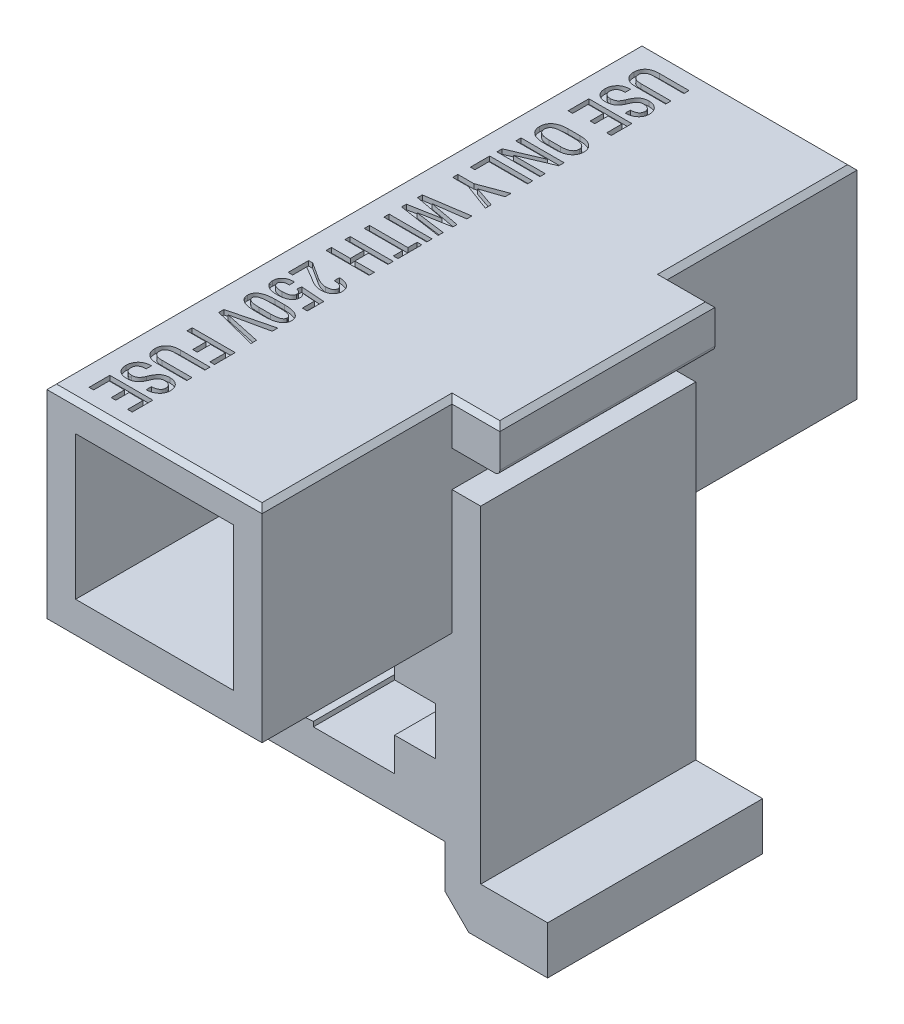
from build123d import *

# Parameters (mm, degrees)
SKETCH_1_W          = 6.6
SKETCH_1_H          = 6
EXTRUDE_910_DEPTH   = 4.5
SKETCH_2_W          = 9
SKETCH_2_H          = 8.5
SKETCH_2_W_2        = 6.6
SKETCH_2_H_2        = 6
EXTRUDE_1336_DEPTH  = 12.45
EXTRUDE_1612_DEPTH  = 2.5
FILLET_1_R          = 0.2
SKETCH_5_W          = 1.8
SKETCH_5_H          = 0.220879121
CUT_EXTRUDE_2_DEPTH = 0.2
CHAMFER_1_SIZE      = 0.2


with BuildPart() as part:
    # Эскиз1 → Extrude 910 (new, symmetric)
    with BuildSketch(Plane.XY):
        Polygon((0, -10), (3.2, -10.2), (3.2, -10), (6.6, -10), (6.6, -11.4), (8.3, -11.4), (8.3, -13.4), (6.6, -13.4), (6.6, -14.8), (3.2, -14.8), (3.2, -14.6), (0, -14.8), (0, -16.2), (8.7, -16.2), (8.7, -18), (9.7, -19), (13, -19), (13, -17), (10.2, -17), (10.2, -3.3), (9, -3.3), (9, -1.8), (11, -1.8), (11, 0), (0, 0), align=None)
        with Locations((4.5, -4.2)):
            Rectangle(SKETCH_1_W, SKETCH_1_H, mode=Mode.SUBTRACT)
    extrude(amount=EXTRUDE_910_DEPTH, both=True)

    # Эскиз2 → Extrude 1336 (add, symmetric)
    with BuildSketch(Plane.XY):
        with Locations((4.5, -4.25)):
            Rectangle(SKETCH_2_W, SKETCH_2_H)
        with Locations((4.5, -4.2)):
            Rectangle(SKETCH_2_W_2, SKETCH_2_H_2, mode=Mode.SUBTRACT)
    extrude(amount=EXTRUDE_1336_DEPTH, both=True)

    # Эскиз3 → Extrude 1612 (add, symmetric)
    with BuildSketch(Plane.XY):
        with BuildLine():
            Line((2.5, -1.2), (2.5, -2.234463617))
            ThreePointArc((2.5, -2.234463617), (2.654992936, -2.497090636), (2.959819676, -2.48834877))
            add(Edge.make_bspline(
                [(6.040180324, -2.48834877), (4.5, -1.518811493), (2.959819676, -2.48834877)],
                knots=[0.437087375, 0.437087375, 0.437087375, 2.704505279, 2.704505279, 2.704505279], degree=2, weights=[1, 0.423302459, 1]))
            ThreePointArc((6.040180324, -2.48834877), (6.345007064, -2.497090636), (6.5, -2.234463617))
            Line((6.5, -2.234463617), (6.5, -1.2))
            Line((6.5, -1.2), (2.5, -1.2))
        make_face()
    extrude(amount=EXTRUDE_1612_DEPTH, both=True)

    # Скругление1
    fillet_1_edges = [part.edges().sort_by_distance(p)[0] for p in [
        (11, -1.8, 0),
    ]]
    fillet(fillet_1_edges, radius=FILLET_1_R)

    # Эскиз5 → Вырез-Вытянуть2 (cut)
    # profile 1 of 19: a face of its own
    with BuildSketch(Plane(origin=(0, 0, 0), x_dir=(1, 0, 0), z_dir=(0, 1, 0))):
        with BuildLine():
            Line((2.8, 10.643956044), (1.552747253, 10.643956044))
            add(Edge.make_bspline(
                [(1.552747253, 10.643956044), (1.529653086, 10.644368303), (1.484842464, 10.645168227), (1.419756028, 10.651613462), (1.358826488, 10.661298779), (1.302526713, 10.676786872), (1.250213908, 10.694960296), (1.20262485, 10.71844193), (1.158965451, 10.745405837), (1.120209836, 10.777175483), (1.085568874, 10.811940625), (1.055747754, 10.850032833), (1.030210482, 10.890822826), (1.00981077, 10.934725437), (0.993486787, 10.981055202), (0.982277417, 11.030339595), (0.975090921, 11.082326443), (0.974363611, 11.118046199), (0.973992674, 11.136263736)],
                knots=[0, 0, 0, 0, 1.285713227, 2.494725674, 3.639351386, 4.716346927, 5.742228908, 6.718347468, 7.665379, 8.59347588, 9.502167367, 10.39310791, 11.281762387, 12.175991834, 13.08343601, 14.011981089, 14.986084709, 16, 16, 16, 16], degree=3))
            add(Edge.make_bspline(
                [(0.973992674, 11.136263736), (0.974353355, 11.154238887), (0.975057974, 11.189354729), (0.982362134, 11.240591464), (0.993435044, 11.289172484), (1.009727494, 11.334807518), (1.030325585, 11.377764389), (1.055748018, 11.41775907), (1.085598491, 11.455103261), (1.120221879, 11.489160116), (1.159098741, 11.520142984), (1.202627081, 11.546783975), (1.250240581, 11.569860769), (1.302535915, 11.58771112), (1.358886389, 11.602673739), (1.419725805, 11.612640189), (1.4848683, 11.618426816), (1.529658019, 11.619319855), (1.552747253, 11.61978022)],
                knots=[0, 0, 0, 0, 1.008087759, 1.969377174, 2.898453435, 3.80001039, 4.682620536, 5.566559556, 6.453679748, 7.359730165, 8.286453594, 9.237208886, 10.217911946, 11.249456112, 12.333052902, 13.486557869, 14.704313053, 16, 16, 16, 16], degree=3))
            Line((1.552747253, 11.61978022), (2.8, 11.61978022))
            Line((2.8, 11.61978022), (2.8, 11.402197802))
            Line((2.8, 11.402197802), (1.552747253, 11.402197802))
            add(Edge.make_bspline(
                [(1.552747253, 11.402197802), (1.536868265, 11.402002615), (1.506172722, 11.401625301), (1.461654611, 11.398288706), (1.420303904, 11.39288154), (1.381894105, 11.385378703), (1.346854182, 11.374969089), (1.314591619, 11.363205809), (1.285985388, 11.348240996), (1.26001764, 11.3319831), (1.237691352, 11.313047156), (1.218078412, 11.292867415), (1.201388576, 11.271041017), (1.187616808, 11.247495737), (1.177520182, 11.221827321), (1.169662611, 11.194777568), (1.1652982, 11.165952959), (1.164748925, 11.146289585), (1.164468864, 11.136263736)],
                knots=[0, 0, 0, 0, 1.433081564, 2.77027844, 4.026549566, 5.195842378, 6.297919398, 7.323384151, 8.289447543, 9.206558402, 10.082830922, 10.924604247, 11.742372131, 12.557089603, 13.377748575, 14.225488684, 15.095222285, 16, 16, 16, 16], degree=3))
            add(Edge.make_bspline(
                [(1.164468864, 11.136263736), (1.164722226, 11.125743617), (1.165216564, 11.105217686), (1.169877557, 11.075445834), (1.176530033, 11.04727459), (1.187041973, 11.021220687), (1.199945241, 10.996717583), (1.215632984, 10.973926129), (1.234618931, 10.953259504), (1.256465223, 10.934421987), (1.281403684, 10.917428493), (1.310138258, 10.903268986), (1.341914003, 10.890695254), (1.377494342, 10.881107633), (1.416331119, 10.87284917), (1.458861358, 10.867685107), (1.504706016, 10.864298292), (1.536378949, 10.863927754), (1.552747253, 10.863736264)],
                knots=[0, 0, 0, 0, 0.935379452, 1.825030123, 2.676164598, 3.505381383, 4.317045097, 5.136812626, 5.959741963, 6.807053905, 7.699023536, 8.636797684, 9.651649978, 10.735134006, 11.911341456, 13.182146826, 14.543757403, 16, 16, 16, 16], degree=3))
            Line((1.552747253, 10.863736264), (2.8, 10.863736264))
            Line((2.8, 10.863736264), (2.8, 10.643956044))
        make_face()
    # profile 2 of 19: a face of its own
    with BuildSketch(Plane(origin=(0, 0, 0), x_dir=(1, 0, 0), z_dir=(0, 1, 0))):
        with BuildLine():
            add(Edge.make_bspline(
                [(1.452380952, 9.684249084), (1.473064094, 9.684920037), (1.512652304, 9.686204263), (1.5689084, 9.696761137), (1.618982792, 9.714637352), (1.655696041, 9.736411729), (1.682483941, 9.757443717), (1.7012975, 9.776786103), (1.720132094, 9.798465473), (1.738420569, 9.823043239), (1.755997544, 9.850609418), (1.772752697, 9.881190398), (1.789292628, 9.914538021), (1.799494976, 9.938046812), (1.804761905, 9.95018315)],
                knots=[0, 0, 0, 0, 1.562131304, 2.989970457, 4.306494377, 5.559837698, 6.19678473, 6.875347781, 7.594954274, 8.366353833, 9.187992889, 10.063608961, 11.000344366, 12, 12, 12, 12], degree=3))
            add(Edge.make_bspline(
                [(1.804761905, 9.95018315), (1.811423262, 9.96820156), (1.824456909, 10.003456479), (1.84649437, 10.0538813), (1.869655852, 10.101093052), (1.893986576, 10.145023966), (1.920117106, 10.185478734), (1.947464614, 10.22249229), (1.976337108, 10.256045613), (2.006217713, 10.286826807), (2.038830116, 10.313711953), (2.073590052, 10.337399691), (2.111566376, 10.356908175), (2.152066476, 10.372938377), (2.19539677, 10.385367722), (2.241175293, 10.394638248), (2.289876937, 10.399623405), (2.32318858, 10.400356288), (2.34029304, 10.400732601)],
                knots=[0, 0, 0, 0, 1.217935212, 2.383018656, 3.487592294, 4.551698414, 5.565372946, 6.539388828, 7.467357411, 8.370710179, 9.255964568, 10.142842657, 11.032824559, 11.957298199, 12.900643214, 13.88762046, 14.915360815, 16, 16, 16, 16], degree=3))
            add(Edge.make_bspline(
                [(2.34029304, 10.400732601), (2.358018992, 10.400464833), (2.392732587, 10.399940451), (2.443306075, 10.393385043), (2.491388362, 10.383614181), (2.536844995, 10.369795114), (2.579750453, 10.35163059), (2.620000035, 10.329682151), (2.657883796, 10.30389011), (2.692275502, 10.273795119), (2.724055514, 10.241089744), (2.751054445, 10.204905667), (2.774385047, 10.166579279), (2.793639297, 10.125636752), (2.808194828, 10.081959658), (2.818365075, 10.035786274), (2.824742147, 9.987234865), (2.825579408, 9.953988373), (2.826007326, 9.936996337)],
                knots=[0, 0, 0, 0, 1.124515011, 2.202192552, 3.231281813, 4.236481171, 5.212480952, 6.183637031, 7.142467189, 8.115137586, 9.079963614, 10.031750853, 10.974182522, 11.924232489, 12.89727338, 13.890115663, 14.921653751, 16, 16, 16, 16], degree=3))
            add(Edge.make_bspline(
                [(2.826007326, 9.936996337), (2.825510307, 9.919509296), (2.824536087, 9.885232454), (2.817020719, 9.835146257), (2.805026334, 9.787716924), (2.788192722, 9.74296737), (2.765847014, 9.70112035), (2.738681257, 9.662026205), (2.706977757, 9.625301825), (2.670269685, 9.592261753), (2.630099752, 9.562529919), (2.587598437, 9.535798636), (2.542284105, 9.513904076), (2.4946829, 9.495945187), (2.444780274, 9.481402293), (2.392216702, 9.47194364), (2.337413167, 9.465242011), (2.300021615, 9.464729989), (2.280952381, 9.464468864)],
                knots=[0, 0, 0, 0, 1.036885918, 2.03242926, 2.996767969, 3.934272482, 4.860859703, 5.803052047, 6.752785154, 7.731993726, 8.725638583, 9.714415197, 10.705549545, 11.70493152, 12.729579591, 13.783523999, 14.869624365, 16, 16, 16, 16], degree=3))
            Line((2.280952381, 9.464468864), (2.280952381, 9.685347985))
            add(Edge.make_bspline(
                [(2.280952381, 9.685347985), (2.294021679, 9.685582917), (2.319461193, 9.686040214), (2.356669434, 9.68889894), (2.391758971, 9.694074034), (2.424980137, 9.700927582), (2.456231449, 9.710085794), (2.485489526, 9.721422907), (2.512712372, 9.734616425), (2.537857537, 9.749639378), (2.560514877, 9.76676855), (2.580508516, 9.785795656), (2.597138481, 9.806966606), (2.610826436, 9.829855891), (2.621477893, 9.854622985), (2.629254633, 9.8811633), (2.633623041, 9.909622588), (2.63415786, 9.929167269), (2.634432234, 9.939194139)],
                knots=[0, 0, 0, 0, 1.278996757, 2.48957959, 3.64877324, 4.747844577, 5.806488387, 6.831629009, 7.814900639, 8.76366329, 9.6932724, 10.589014924, 11.456745892, 12.319444101, 13.191769743, 14.087910641, 15.019054267, 16, 16, 16, 16], degree=3))
            add(Edge.make_bspline(
                [(2.634432234, 9.939194139), (2.634304728, 9.948736259), (2.634056632, 9.967302969), (2.629730135, 9.994134199), (2.623612001, 10.019345354), (2.614935783, 10.042804116), (2.603328765, 10.06439319), (2.589274712, 10.084276169), (2.57289242, 10.102733074), (2.5469051, 10.124209563), (2.510167636, 10.14726782), (2.459452978, 10.166170912), (2.403005474, 10.178186859), (2.363191638, 10.179283363), (2.342490842, 10.17985348)],
                knots=[0, 0, 0, 0, 0.802021316, 1.560543999, 2.280728389, 2.983026886, 3.658741603, 4.337184916, 5.028346535, 5.728235768, 7.16805474, 8.654485078, 10.260533812, 12, 12, 12, 12], degree=3))
            add(Edge.make_bspline(
                [(2.342490842, 10.17985348), (2.323731557, 10.179177187), (2.287472252, 10.177869999), (2.235581965, 10.164993619), (2.188581526, 10.144053923), (2.153974617, 10.119024937), (2.128585188, 10.095079173), (2.109948216, 10.074043358), (2.091533299, 10.050289432), (2.074291962, 10.02315157), (2.055902964, 9.9940462), (2.039112162, 9.961330936), (2.022048054, 9.926120575), (2.011609466, 9.90139416), (2.006227106, 9.888644689)],
                knots=[0, 0, 0, 0, 1.411650332, 2.728539836, 4.001213019, 5.267849563, 5.925377249, 6.629249922, 7.383929009, 8.187943363, 9.051283996, 9.977518369, 10.957165011, 12, 12, 12, 12], degree=3))
            add(Edge.make_bspline(
                [(2.006227106, 9.888644689), (1.999710993, 9.871347374), (1.986952192, 9.837478563), (1.964902375, 9.789232487), (1.941428425, 9.744351892), (1.916461442, 9.702685771), (1.889845888, 9.664340109), (1.861682921, 9.629203201), (1.831283842, 9.598112361), (1.799943605, 9.569446231), (1.765721334, 9.54487462), (1.729458781, 9.522865978), (1.689989461, 9.50533636), (1.648323288, 9.489773745), (1.603609841, 9.478974686), (1.556459664, 9.470194188), (1.506557811, 9.465687716), (1.47241248, 9.464881363), (1.454945055, 9.464468864)],
                knots=[0, 0, 0, 0, 1.179928657, 2.310345955, 3.384407641, 4.412585788, 5.409581103, 6.36294743, 7.283720604, 8.183663037, 9.070954501, 9.969443695, 10.886943557, 11.824106363, 12.805463855, 13.819355269, 14.884466877, 16, 16, 16, 16], degree=3))
            add(Edge.make_bspline(
                [(1.454945055, 9.464468864), (1.43660896, 9.464732339), (1.40080045, 9.465246879), (1.348645373, 9.47182358), (1.299598654, 9.481480823), (1.253477848, 9.495035414), (1.210709751, 9.513037066), (1.170729294, 9.534751531), (1.133903974, 9.560456905), (1.100576086, 9.590196954), (1.07086324, 9.623334813), (1.044680384, 9.659152297), (1.023105174, 9.698070113), (1.004923386, 9.739307753), (0.991002836, 9.783541977), (0.981391224, 9.830568051), (0.9747733, 9.880155046), (0.974256611, 9.914140979), (0.973992674, 9.931501832)],
                knots=[0, 0, 0, 0, 1.158591607, 2.262610455, 3.317834137, 4.316776784, 5.295987146, 6.246006859, 7.188311029, 8.128779395, 9.063495607, 9.997701637, 10.927463686, 11.871189725, 12.842885681, 13.852745409, 14.903129434, 16, 16, 16, 16], degree=3))
            add(Edge.make_bspline(
                [(0.973992674, 9.931501832), (0.974398743, 9.948618597), (0.975199481, 9.982371611), (0.982035159, 10.032028041), (0.992840417, 10.079961428), (1.008852862, 10.125837908), (1.028745704, 10.170124098), (1.052797811, 10.212819625), (1.082171182, 10.253021255), (1.114818979, 10.291667646), (1.152197546, 10.326794793), (1.19366701, 10.357864682), (1.239668538, 10.383470715), (1.289330812, 10.404850311), (1.343147118, 10.421316277), (1.400841609, 10.43271621), (1.462428519, 10.440458798), (1.504858601, 10.441074448), (1.526739927, 10.441391941)],
                knots=[0, 0, 0, 0, 0.970082726, 1.912932519, 2.836550248, 3.751671045, 4.662645183, 5.586574191, 6.524122738, 7.481499719, 8.451187138, 9.425927293, 10.411692308, 11.428873971, 12.486524008, 13.595751359, 14.760121493, 16, 16, 16, 16], degree=3))
            Line((1.526739927, 10.441391941), (1.526739927, 10.220512821))
            add(Edge.make_bspline(
                [(1.526739927, 10.220512821), (1.511347738, 10.220347189), (1.481736435, 10.220028549), (1.438895167, 10.216333607), (1.399378274, 10.210124474), (1.362923231, 10.201869514), (1.329725237, 10.190968277), (1.299894316, 10.177219609), (1.27289173, 10.161751281), (1.249578539, 10.143089964), (1.229474195, 10.122422346), (1.211649107, 10.100316644), (1.196601277, 10.07649735), (1.184361105, 10.050789312), (1.174857625, 10.023400689), (1.168357449, 9.994138318), (1.164247906, 9.96336406), (1.163666395, 9.942259911), (1.163369963, 9.931501832)],
                knots=[0, 0, 0, 0, 1.396148919, 2.685894102, 3.896984594, 5.022854719, 6.073749873, 7.060199081, 7.99871115, 8.88966808, 9.759156373, 10.610316575, 11.461620932, 12.308879692, 13.188191438, 14.085734925, 15.024181617, 16, 16, 16, 16], degree=3))
            add(Edge.make_bspline(
                [(1.163369963, 9.931501832), (1.163535983, 9.921842091), (1.163860898, 9.902937216), (1.167705952, 9.875491342), (1.173388679, 9.849647637), (1.181847498, 9.825645556), (1.192911779, 9.803563369), (1.206288813, 9.783247201), (1.221659665, 9.764345745), (1.2459646, 9.741750327), (1.282063896, 9.718083017), (1.332605679, 9.69847982), (1.390139595, 9.686209881), (1.430946368, 9.684924341), (1.452380952, 9.684249084)],
                knots=[0, 0, 0, 0, 0.804902542, 1.575257773, 2.306329089, 3.008322246, 3.691304701, 4.360565555, 5.033225263, 5.71749658, 7.120929047, 8.601284655, 10.21475592, 12, 12, 12, 12], degree=3))
        make_face()
    # profile 3 of 19: a face of its own
    with BuildSketch(Plane(origin=(0, 0, 0), x_dir=(1, 0, 0), z_dir=(0, 1, 0))):
        Polygon((1.835897436, 8.447619048), (1.835897436, 9.005860806), (1.19047619, 9.005860806), (1.19047619, 8.357509158), (1, 8.357509158), (1, 9.226739927), (2.8, 9.226739927), (2.8, 8.363003663), (2.607326007, 8.363003663), (2.607326007, 9.005860806), (2.027472527, 9.005860806), (2.027472527, 8.447619048), align=None)
    # profile 4 of 19: a face of its own
    with BuildSketch(Plane(origin=(0, 0, 0), x_dir=(1, 0, 0), z_dir=(0, 1, 0))):
        with BuildLine():
            add(Edge.make_bspline(
                [(1.651648352, 6.678388278), (1.625258379, 6.678775891), (1.573857356, 6.679530863), (1.499254152, 6.68635002), (1.429131391, 6.696584101), (1.363929375, 6.712129911), (1.303111784, 6.731274199), (1.247200374, 6.755353131), (1.195484167, 6.782869353), (1.149277293, 6.815714614), (1.108213104, 6.852113463), (1.071726449, 6.891305104), (1.041677457, 6.934534161), (1.017055076, 6.98070272), (0.997157971, 7.029815043), (0.984112733, 7.082497994), (0.975141127, 7.138154926), (0.974381489, 7.176396831), (0.973992674, 7.195970696)],
                knots=[0, 0, 0, 0, 1.313978048, 2.559298395, 3.728047241, 4.840168003, 5.894005044, 6.89926583, 7.867941638, 8.805995934, 9.714981633, 10.597297047, 11.466098001, 12.328512588, 13.199120512, 14.097323178, 15.026127528, 16, 16, 16, 16], degree=3))
            add(Edge.make_bspline(
                [(0.973992674, 7.195970696), (0.974377784, 7.215300526), (0.975127602, 7.252936161), (0.984081957, 7.307634626), (0.997318841, 7.359398483), (1.016876419, 7.407797248), (1.041702361, 7.453046982), (1.071872595, 7.495189839), (1.108125439, 7.533611161), (1.149315378, 7.568950267), (1.195731485, 7.600542627), (1.24710029, 7.627936564), (1.303240571, 7.650986523), (1.363870457, 7.670097485), (1.429246346, 7.684462088), (1.499216439, 7.695161707), (1.573883775, 7.701269484), (1.625263801, 7.702124855), (1.651648352, 7.702564103)],
                knots=[0, 0, 0, 0, 0.969502548, 1.887644309, 2.775321219, 3.647280498, 4.500507326, 5.361341538, 6.241792457, 7.146057014, 8.081210543, 9.054812977, 10.063448489, 11.123952136, 12.242317787, 13.4205215, 14.67539222, 16, 16, 16, 16], degree=3))
            Line((1.651648352, 7.702564103), (2.146153846, 7.702564103))
            add(Edge.make_bspline(
                [(2.146153846, 7.702564103), (2.172417039, 7.70212951), (2.223554688, 7.701283306), (2.298088135, 7.69509367), (2.367961887, 7.684552903), (2.433313338, 7.670048901), (2.493915892, 7.65090473), (2.550254804, 7.628036911), (2.601782156, 7.60046061), (2.648466081, 7.568815572), (2.690436102, 7.533900472), (2.726452794, 7.494964794), (2.757713041, 7.453527462), (2.782717504, 7.408319403), (2.802236637, 7.35997241), (2.816172353, 7.308465423), (2.824235414, 7.253733678), (2.825407044, 7.216266058), (2.826007326, 7.197069597)],
                knots=[0, 0, 0, 0, 1.318288415, 2.566868808, 3.75096063, 4.863184467, 5.923533954, 6.937687672, 7.911148577, 8.85123492, 9.764710117, 10.64503305, 11.508030526, 12.364100571, 13.230248278, 14.119381983, 15.036469066, 16, 16, 16, 16], degree=3))
            add(Edge.make_bspline(
                [(2.826007326, 7.197069597), (2.825406364, 7.177507467), (2.824232972, 7.139311939), (2.81617269, 7.083488437), (2.802233482, 7.030894612), (2.782744122, 6.981439034), (2.757623302, 6.935109037), (2.726608934, 6.892270803), (2.690467575, 6.852209739), (2.648501108, 6.816202811), (2.601927306, 6.783382403), (2.550267747, 6.755169105), (2.494026769, 6.7313868), (2.433258559, 6.712170823), (2.368076681, 6.696493054), (2.298050461, 6.686418929), (2.223581115, 6.679517381), (2.172422447, 6.678771347), (2.146153846, 6.678388278)],
                knots=[0, 0, 0, 0, 0.972237541, 1.898317176, 2.796289293, 3.670822251, 4.534420997, 5.408532696, 6.293594378, 7.209918381, 8.151087683, 9.120764728, 10.129627484, 11.181387851, 12.285411261, 13.45785677, 14.694677809, 16, 16, 16, 16], degree=3))
            Line((2.146153846, 6.678388278), (1.651648352, 6.678388278))
        make_face()
        with BuildLine():
            add(Edge.make_bspline(
                [(2.14981685, 6.899267399), (2.169116369, 6.899421641), (2.206410027, 6.899719691), (2.260544587, 6.903609547), (2.310977795, 6.909141213), (2.357687419, 6.91764783), (2.400663722, 6.928185487), (2.440089151, 6.940873414), (2.475847062, 6.956223706), (2.507850719, 6.974224188), (2.536303862, 6.994400895), (2.560950651, 7.016745697), (2.581928583, 7.041267359), (2.598821278, 7.06822487), (2.612099941, 7.09742528), (2.621649406, 7.128681177), (2.627231089, 7.162192982), (2.627873753, 7.185204326), (2.628205128, 7.197069597)],
                knots=[0, 0, 0, 0, 1.458012894, 2.817408669, 4.099162608, 5.289958794, 6.402097135, 7.440779738, 8.416018391, 9.337260085, 10.210300907, 11.046284175, 11.844876056, 12.640959069, 13.441945694, 14.262046119, 15.103863963, 16, 16, 16, 16], degree=3))
            add(Edge.make_bspline(
                [(2.628205128, 7.197069597), (2.627870092, 7.208447515), (2.627217468, 7.230610758), (2.621632906, 7.262903836), (2.612186874, 7.29299956), (2.598696977, 7.320888517), (2.581912567, 7.346689715), (2.560897071, 7.370087846), (2.536250795, 7.391326951), (2.507800946, 7.410410528), (2.475716812, 7.427244864), (2.440002065, 7.441857977), (2.400649741, 7.454208019), (2.357715339, 7.464534055), (2.31089321, 7.471902864), (2.260572399, 7.477903665), (2.206390056, 7.481077263), (2.169112244, 7.481477707), (2.14981685, 7.481684982)],
                knots=[0, 0, 0, 0, 0.871900125, 1.698389418, 2.503717588, 3.282545406, 4.066700235, 4.855813006, 5.685424632, 6.555261681, 7.476573926, 8.458844122, 9.509906415, 10.636160325, 11.841247002, 13.141822852, 14.520576921, 16, 16, 16, 16], degree=3))
            Line((2.14981685, 7.481684982), (1.651648352, 7.481684982))
            add(Edge.make_bspline(
                [(1.651648352, 7.481684982), (1.632108852, 7.481474892), (1.594221354, 7.481067523), (1.539185599, 7.477913066), (1.488125188, 7.471940648), (1.440714265, 7.464474879), (1.397261884, 7.454271308), (1.357449501, 7.441834093), (1.321434552, 7.427337577), (1.28928486, 7.410385615), (1.260851209, 7.391436337), (1.236389949, 7.369958155), (1.215644085, 7.346349014), (1.198606187, 7.320466988), (1.185431459, 7.292436114), (1.175668595, 7.262332714), (1.170245036, 7.22986728), (1.169574783, 7.207467563), (1.169230769, 7.195970696)],
                knots=[0, 0, 0, 0, 1.486209938, 2.881792185, 4.190460938, 5.395112332, 6.530467681, 7.582012683, 8.565050898, 9.479024523, 10.341932972, 11.157937373, 11.947729972, 12.725638694, 13.506645785, 14.296711357, 15.125770979, 16, 16, 16, 16], degree=3))
            add(Edge.make_bspline(
                [(1.169230769, 7.195970696), (1.169562741, 7.184105832), (1.170206562, 7.161095279), (1.175780039, 7.127577869), (1.185359273, 7.096342304), (1.198487512, 7.067162498), (1.215753399, 7.040474411), (1.236208838, 7.015759846), (1.260944483, 6.993610619), (1.2891123, 6.97343105), (1.321422385, 6.955854545), (1.357343023, 6.940490103), (1.397257951, 6.927793476), (1.440699549, 6.917224497), (1.488087401, 6.909242674), (1.539205662, 6.903558505), (1.594203843, 6.899741904), (1.63210552, 6.899428827), (1.651648352, 6.899267399)],
                knots=[0, 0, 0, 0, 0.8911907, 1.728362962, 2.543937654, 3.340504024, 4.124446398, 4.925649522, 5.744057957, 6.612280894, 7.523971076, 8.502254607, 9.543929799, 10.66775118, 11.859417063, 13.152327948, 14.531685729, 16, 16, 16, 16], degree=3))
            Line((1.651648352, 6.899267399), (2.14981685, 6.899267399))
        make_face(mode=Mode.SUBTRACT)
    # profile 5 of 19: a face of its own
    with BuildSketch(Plane(origin=(0, 0, 0), x_dir=(1, 0, 0), z_dir=(0, 1, 0))):
        Polygon((1, 5.38021978), (1, 5.6), (2.327838828, 6.165934066), (2.326373626, 6.169230769), (1, 6.169230769), (1, 6.39010989), (2.8, 6.39010989), (2.8, 6.169230769), (1.474725275, 5.603296703), (1.475824176, 5.6), (2.8, 5.6), (2.8, 5.38021978), align=None)
    # profile 6 of 19: a face of its own
    with BuildSketch(Plane(origin=(0, 0, 0), x_dir=(1, 0, 0), z_dir=(0, 1, 0))):
        Polygon((1.19047619, 4.856410256), (1.19047619, 4.268498168), (1, 4.268498168), (1, 5.077289377), (2.8, 5.077289377), (2.8, 4.856410256), align=None)
    # profile 7 of 19: a face of its own
    with BuildSketch(Plane(origin=(0, 0, 0), x_dir=(1, 0, 0), z_dir=(0, 1, 0))):
        Polygon((1.940659341, 3.632600733), (2.8, 3.34029304), (2.8, 3.096336996), (1.649084249, 3.527106227), (1, 3.527106227), (1, 3.744688645), (1.667765568, 3.744688645), (2.8, 4.168864469), (2.8, 3.924908425), align=None)
    # profile 8 of 19: a face of its own
    with BuildSketch(Plane(origin=(0, 0, 0), x_dir=(1, 0, 0), z_dir=(0, 1, 0))):
        Polygon((1.535164835, 1.503296703), (1.535164835, 1.5), (2.8, 1.32967033), (2.8, 1.116483516), (1, 1.389010989), (1, 1.586813187), (2.262271062, 1.821978022), (2.262271062, 1.825274725), (1, 2.06043956), (1, 2.258241758), (2.8, 2.530769231), (2.8, 2.317582418), (1.531501832, 2.145054945), (1.531501832, 2.141758242), (2.8, 1.908791209), (2.8, 1.738461538), align=None)
    # profile 9 of 19: a face of its own
    with BuildSketch(Plane(origin=(0, 0, 0), x_dir=(1, 0, 0), z_dir=(0, 1, 0))):
        with Locations((1.9, 0.757326008)):
            Rectangle(SKETCH_5_W, SKETCH_5_H)
    # profile 10 of 19: a face of its own
    with BuildSketch(Plane(origin=(0, 0, 0), x_dir=(1, 0, 0), z_dir=(0, 1, 0))):
        Polygon((2.607326007, -0.56043956), (2.607326007, -0.171428571), (1, -0.171428571), (1, 0.047252747), (2.607326007, 0.047252747), (2.607326007, 0.435164835), (2.8, 0.435164835), (2.8, -0.56043956), align=None)
    # profile 11 of 19: a face of its own
    with BuildSketch(Plane(origin=(0, 0, 0), x_dir=(1, 0, 0), z_dir=(0, 1, 0))):
        Polygon((1, -1.76996337), (1, -1.549084249), (1.793772894, -1.549084249), (1.793772894, -0.980952381), (1, -0.980952381), (1, -0.76007326), (2.8, -0.76007326), (2.8, -0.980952381), (1.985347985, -0.980952381), (1.985347985, -1.549084249), (2.8, -1.549084249), (2.8, -1.76996337), align=None)
    # profile 12 of 19: a face of its own
    with BuildSketch(Plane(origin=(0, 0, 0), x_dir=(1, 0, 0), z_dir=(0, 1, 0))):
        with BuildLine():
            Line((1, -3.357142857), (1, -2.5))
            Line((1, -2.5), (1.167032967, -2.5))
            Line((1.167032967, -2.5), (1.817216117, -2.917582418))
            add(Edge.make_bspline(
                [(1.817216117, -2.917582418), (1.831241036, -2.92579213), (1.858480049, -2.941736924), (1.898346221, -2.964436367), (1.936160558, -2.985281715), (1.972436721, -3.003111872), (2.006140003, -3.020467462), (2.038239538, -3.034948888), (2.068343559, -3.047393305), (2.105375344, -3.061711862), (2.150596188, -3.075622031), (2.204555836, -3.087947741), (2.258299595, -3.094996718), (2.293998198, -3.096137118), (2.311721612, -3.096703297)],
                knots=[0, 0, 0, 0, 1.098193461, 2.132896823, 3.10026747, 4.015414222, 4.864132133, 5.661735444, 6.394194987, 7.065393678, 8.344206655, 9.587330306, 10.802173213, 12, 12, 12, 12], degree=3))
            add(Edge.make_bspline(
                [(2.311721612, -3.096703297), (2.334711039, -3.096234542), (2.378572499, -3.095340207), (2.440773879, -3.086124757), (2.496083275, -3.071386308), (2.536948219, -3.053610141), (2.565024309, -3.036137626), (2.583091144, -3.022173259), (2.598771285, -3.007185415), (2.61130268, -2.990569758), (2.620991122, -2.972640436), (2.628007031, -2.953542144), (2.632066109, -2.933136078), (2.632663156, -2.919187353), (2.632967033, -2.912087912)],
                knots=[0, 0, 0, 0, 2.010332215, 3.835506842, 5.4865274, 7.007354078, 7.712875454, 8.375344066, 9.002407891, 9.604966045, 10.188176453, 10.779645979, 11.378880043, 12, 12, 12, 12], degree=3))
            add(Edge.make_bspline(
                [(2.632967033, -2.912087912), (2.632737163, -2.903149344), (2.632286527, -2.885626226), (2.627272698, -2.860447263), (2.620009285, -2.836829056), (2.609461492, -2.815037685), (2.595048604, -2.795623409), (2.578700171, -2.777242987), (2.558400931, -2.761644943), (2.535763576, -2.74730648), (2.510221872, -2.734984148), (2.482369958, -2.723872799), (2.45187902, -2.715013033), (2.419203971, -2.7069918), (2.383952185, -2.70201134), (2.34650274, -2.697327397), (2.306505048, -2.69483511), (2.279001603, -2.694617553), (2.264835165, -2.694505495)],
                knots=[0, 0, 0, 0, 0.892226533, 1.749115872, 2.555779177, 3.358091866, 4.153974395, 4.965882701, 5.808310582, 6.70220483, 7.6409594, 8.638106989, 9.69598813, 10.811968, 11.997764812, 13.251155143, 14.584128599, 16, 16, 16, 16], degree=3))
            Line((2.264835165, -2.694505495), (2.264835165, -2.474725275))
            add(Edge.make_bspline(
                [(2.264835165, -2.474725275), (2.284753162, -2.475045546), (2.323691123, -2.475671649), (2.380677499, -2.481484641), (2.435142992, -2.489889411), (2.486837852, -2.502983641), (2.536086487, -2.518863295), (2.582519362, -2.53880263), (2.626288748, -2.562316969), (2.667232362, -2.589268567), (2.704466376, -2.619395055), (2.73718369, -2.652515635), (2.764382603, -2.688939285), (2.787510373, -2.727743142), (2.804603396, -2.770087304), (2.817127302, -2.814909214), (2.824530587, -2.862637757), (2.82550701, -2.895334314), (2.826007326, -2.912087912)],
                knots=[0, 0, 0, 0, 1.195714929, 2.337519273, 3.43686419, 4.502082901, 5.536212681, 6.541342879, 7.53206196, 8.516329613, 9.480538189, 10.40346707, 11.303869151, 12.204271232, 13.108397385, 14.037017317, 14.994174709, 16, 16, 16, 16], degree=3))
            add(Edge.make_bspline(
                [(2.826007326, -2.912087912), (2.825569026, -2.927613959), (2.824712914, -2.957940261), (2.818520276, -3.002070269), (2.807784489, -3.043584461), (2.792897532, -3.082559728), (2.773174894, -3.118693072), (2.749629867, -3.152403273), (2.721500516, -3.18318264), (2.68969808, -3.211484791), (2.653837335, -3.236287993), (2.615096596, -3.258394697), (2.573008659, -3.276620806), (2.528045692, -3.291731465), (2.479981538, -3.303300794), (2.428949477, -3.31178989), (2.37493161, -3.316386388), (2.337981118, -3.317177203), (2.319047619, -3.317582418)],
                knots=[0, 0, 0, 0, 1.016289941, 1.985071554, 2.909852686, 3.81832271, 4.708892892, 5.598170728, 6.503646736, 7.432323297, 8.3792253, 9.352842381, 10.347880174, 11.376667233, 12.454586972, 13.580772723, 14.760383602, 16, 16, 16, 16], degree=3))
            add(Edge.make_bspline(
                [(2.319047619, -3.317582418), (2.292874365, -3.316801293), (2.240615501, -3.31524166), (2.162950903, -3.302810455), (2.086839617, -3.282077885), (2.011126273, -3.253262035), (1.934334054, -3.215386317), (1.852830729, -3.171173477), (1.766813573, -3.118203129), (1.70887529, -3.078751635), (1.678754579, -3.058241758)],
                knots=[0, 0, 0, 0, 0.894210851, 1.785427353, 2.680300092, 3.586322125, 4.549419217, 5.604506896, 6.754641101, 8, 8, 8, 8], degree=3))
            Line((1.678754579, -3.058241758), (1.19047619, -2.775824176))
            Line((1.19047619, -2.775824176), (1.19047619, -3.357142857))
            Line((1.19047619, -3.357142857), (1, -3.357142857))
        make_face()
    # profile 13 of 19: a face of its own
    with BuildSketch(Plane(origin=(0, 0, 0), x_dir=(1, 0, 0), z_dir=(0, 1, 0))):
        with BuildLine():
            Line((1.808424908, -3.595604396), (2.8, -3.669230769))
            Line((2.8, -3.669230769), (2.8, -4.353846154))
            Line((2.8, -4.353846154), (2.593406593, -4.353846154))
            Line((2.593406593, -4.353846154), (2.593406593, -3.851648352))
            Line((2.593406593, -3.851648352), (2.065567766, -3.813186813))
            Line((2.065567766, -3.813186813), (2.064468864, -3.816483516))
            add(Edge.make_bspline(
                [(2.064468864, -3.816483516), (2.078559206, -3.82891413), (2.1067366, -3.853772456), (2.134010123, -3.892678077), (2.15114273, -3.926666848), (2.161116539, -3.954152205), (2.16746654, -3.98361461), (2.168873999, -4.003876395), (2.16959707, -4.014285714)],
                knots=[0, 0, 0, 0, 1.459220969, 2.918101204, 3.662171757, 4.420024236, 5.188300935, 6, 6, 6, 6], degree=3))
            add(Edge.make_bspline(
                [(2.16959707, -4.014285714), (2.16952533, -4.029211494), (2.169384508, -4.058510385), (2.162096736, -4.101080227), (2.150374093, -4.141081529), (2.133839696, -4.178615225), (2.111661338, -4.213270476), (2.084010393, -4.244887939), (2.05209137, -4.274486817), (2.014819835, -4.300674932), (1.973278205, -4.324059893), (1.92771304, -4.344636172), (1.878245798, -4.361658631), (1.824966735, -4.37562965), (1.76791373, -4.386425606), (1.706906822, -4.394508038), (1.642079579, -4.399284428), (1.597566096, -4.399757339), (1.574725275, -4.4)],
                knots=[0, 0, 0, 0, 0.89644804, 1.759702572, 2.586936947, 3.398970892, 4.217949097, 5.051160114, 5.919149964, 6.830071015, 7.783800393, 8.783014735, 9.832819845, 10.92655648, 12.093210945, 13.322972728, 14.626360005, 16, 16, 16, 16], degree=3))
            add(Edge.make_bspline(
                [(1.574725275, -4.4), (1.55249682, -4.399593432), (1.509209282, -4.398801683), (1.44592805, -4.394245007), (1.386177952, -4.385600104), (1.329627731, -4.374629128), (1.276639962, -4.359479557), (1.227102944, -4.341107722), (1.180577054, -4.319975614), (1.137801978, -4.295180522), (1.099109954, -4.267092322), (1.065547499, -4.23551384), (1.037212299, -4.200511741), (1.014116074, -4.162282968), (0.995947514, -4.120795551), (0.983212598, -4.076076776), (0.97535265, -4.028116061), (0.974454281, -3.99502506), (0.973992674, -3.978021978)],
                knots=[0, 0, 0, 0, 1.288444502, 2.509107787, 3.674035884, 4.78570792, 5.845252531, 6.864026338, 7.845622913, 8.803280489, 9.72471949, 10.610777141, 11.466208827, 12.326689589, 13.191813789, 14.08319654, 15.015092802, 16, 16, 16, 16], degree=3))
            add(Edge.make_bspline(
                [(0.973992674, -3.978021978), (0.974268766, -3.96370992), (0.974814266, -3.935432302), (0.98140414, -3.894123576), (0.991113705, -3.854518025), (1.005267046, -3.817042118), (1.022793355, -3.781093987), (1.04493732, -3.747457021), (1.070964519, -3.71568782), (1.100392955, -3.685559801), (1.134288453, -3.658541861), (1.171759227, -3.634378892), (1.213688686, -3.614818804), (1.259079841, -3.598168535), (1.30863888, -3.585987489), (1.361747712, -3.576840168), (1.418808904, -3.571297684), (1.458107124, -3.570659188), (1.478388278, -3.57032967)],
                knots=[0, 0, 0, 0, 0.937722925, 1.852743361, 2.736393695, 3.607989204, 4.474604864, 5.354109485, 6.24203061, 7.164970125, 8.110388085, 9.078888433, 10.081735532, 11.138016767, 12.245011437, 13.423217929, 14.670165899, 16, 16, 16, 16], degree=3))
            Line((1.478388278, -3.57032967), (1.483516484, -3.784615385))
            add(Edge.make_bspline(
                [(1.483516484, -3.784615385), (1.470934132, -3.784708683), (1.446473807, -3.784890057), (1.410918024, -3.787648361), (1.377599955, -3.791397322), (1.34669368, -3.797417527), (1.317960357, -3.804552027), (1.291659197, -3.813740044), (1.267510153, -3.824299458), (1.246058614, -3.836808673), (1.22668503, -3.850277496), (1.210342481, -3.865409815), (1.195941221, -3.881220989), (1.184848907, -3.898632282), (1.175147229, -3.916658791), (1.169355963, -3.936255639), (1.164817206, -3.956691373), (1.164586969, -3.970789887), (1.164468864, -3.978021978)],
                knots=[0, 0, 0, 0, 1.448842201, 2.816576255, 4.105696248, 5.308293194, 6.440754855, 7.512650962, 8.513652162, 9.47133246, 10.368883616, 11.22504318, 12.032088402, 12.823917827, 13.597553464, 14.380338855, 15.169165124, 16, 16, 16, 16], degree=3))
            add(Edge.make_bspline(
                [(1.164468864, -3.978021978), (1.164868371, -3.986343874), (1.16564479, -4.002517), (1.17030325, -4.025987274), (1.178968691, -4.047570927), (1.190878894, -4.067445614), (1.205703735, -4.086147584), (1.224202828, -4.102938888), (1.246023204, -4.118041757), (1.2711536, -4.131019525), (1.299013497, -4.14287126), (1.330051437, -4.152451812), (1.363580428, -4.161420079), (1.400100824, -4.168159353), (1.439189742, -4.173778023), (1.48115827, -4.177095778), (1.52584622, -4.179975855), (1.556648922, -4.180136809), (1.572527473, -4.18021978)],
                knots=[0, 0, 0, 0, 0.790697116, 1.536674438, 2.260231162, 2.988142514, 3.730686714, 4.518572529, 5.351753576, 6.244013187, 7.20029267, 8.223490688, 9.326082079, 10.495096791, 11.748065503, 13.075153481, 14.492264628, 16, 16, 16, 16], degree=3))
            add(Edge.make_bspline(
                [(1.572527473, -4.18021978), (1.587428031, -4.180120436), (1.616520199, -4.179926474), (1.659039767, -4.177217237), (1.699245089, -4.17325751), (1.737077928, -4.167942176), (1.772259986, -4.160520046), (1.8051282, -4.151863155), (1.835542353, -4.141142124), (1.863673759, -4.12924007), (1.889132733, -4.115821147), (1.91123827, -4.100513397), (1.929770956, -4.083339503), (1.945453009, -4.065136064), (1.957256234, -4.04497511), (1.965971667, -4.023431908), (1.970590098, -4.000070581), (1.971387502, -3.984022602), (1.971794872, -3.975824176)],
                knots=[0, 0, 0, 0, 1.439458306, 2.810429105, 4.114599334, 5.342534185, 6.499387079, 7.586848151, 8.624067613, 9.612364874, 10.536022771, 11.400045753, 12.201564732, 12.971917253, 13.712424002, 14.448500772, 15.207386094, 16, 16, 16, 16], degree=3))
            add(Edge.make_bspline(
                [(1.971794872, -3.975824176), (1.971293549, -3.961733721), (1.970358695, -3.935458186), (1.96199822, -3.898918233), (1.947775178, -3.868367314), (1.926913078, -3.843805525), (1.900189978, -3.824634518), (1.868089227, -3.808577236), (1.8300978, -3.79497053), (1.802287451, -3.788921007), (1.787545788, -3.785714286)],
                knots=[0, 0, 0, 0, 1.145182734, 2.135508634, 3.028583905, 3.860442665, 4.726705525, 5.68636246, 6.773590877, 8, 8, 8, 8], degree=3))
            Line((1.787545788, -3.785714286), (1.808424908, -3.595604396))
        make_face()
    # profile 14 of 19: a face of its own
    with BuildSketch(Plane(origin=(0, 0, 0), x_dir=(1, 0, 0), z_dir=(0, 1, 0))):
        with BuildLine():
            add(Edge.make_bspline(
                [(1.695970696, -5.452747253), (1.667147027, -5.452389978), (1.611405526, -5.451699052), (1.53034999, -5.446554676), (1.45473825, -5.438032172), (1.384433938, -5.425489191), (1.319617965, -5.410011947), (1.260074494, -5.390863907), (1.205785607, -5.368517157), (1.157252174, -5.34190954), (1.114033838, -5.312769285), (1.076806796, -5.28025983), (1.044917159, -5.245421013), (1.018940187, -5.207559427), (0.998607315, -5.167044334), (0.984214389, -5.123631775), (0.975691404, -5.077501559), (0.974566356, -5.045823509), (0.973992674, -5.02967033)],
                knots=[0, 0, 0, 0, 1.478653524, 2.859537637, 4.164887372, 5.38013413, 6.521124747, 7.580938911, 8.586083923, 9.52794759, 10.4157905, 11.254919447, 12.057625933, 12.832550537, 13.602929941, 14.375471014, 15.171624885, 16, 16, 16, 16], degree=3))
            add(Edge.make_bspline(
                [(0.973992674, -5.02967033), (0.974565926, -5.013516858), (0.975690132, -4.981838236), (0.984219187, -4.935712144), (0.998589914, -4.892284504), (1.019050745, -4.851735089), (1.044788064, -4.813586831), (1.076823595, -4.778725118), (1.11403097, -4.74620639), (1.157244849, -4.717046572), (1.205862909, -4.690512848), (1.260051046, -4.667738872), (1.319553414, -4.648143302), (1.38444212, -4.632780715), (1.454735819, -4.620201223), (1.530350699, -4.611689523), (1.611405329, -4.60654203), (1.66714696, -4.60585155), (1.695970696, -4.605494505)],
                knots=[0, 0, 0, 0, 0.827880883, 1.623559745, 2.395639898, 3.165559672, 3.945191713, 4.747419282, 5.58604758, 6.473360778, 7.414662501, 8.421643269, 9.482765943, 10.623075813, 11.837597519, 13.142168445, 14.522228683, 16, 16, 16, 16], degree=3))
            Line((1.695970696, -4.605494505), (2.102930403, -4.605494505))
            add(Edge.make_bspline(
                [(2.102930403, -4.605494505), (2.131631008, -4.605859769), (2.187248521, -4.606567595), (2.268073283, -4.611618429), (2.343501956, -4.620385258), (2.413662433, -4.632232211), (2.478455435, -4.647921387), (2.53795441, -4.667337145), (2.5923452, -4.689891979), (2.641393452, -4.715873206), (2.68471057, -4.745159555), (2.72254598, -4.777236544), (2.75471382, -4.811987684), (2.780603886, -4.849880815), (2.801019978, -4.89024675), (2.815883389, -4.933439932), (2.824280815, -4.979649929), (2.825424263, -5.011322263), (2.826007326, -5.027472527)],
                knots=[0, 0, 0, 0, 1.472645427, 2.853768288, 4.153120441, 5.367494971, 6.502595744, 7.570488263, 8.575807058, 9.520371886, 10.413547064, 11.253475605, 12.060538898, 12.835597482, 13.600511483, 14.375190143, 15.171481664, 16, 16, 16, 16], degree=3))
            add(Edge.make_bspline(
                [(2.826007326, -5.027472527), (2.825434279, -5.043746685), (2.824314601, -5.075544807), (2.815821647, -5.121971154), (2.801049296, -5.165438191), (2.780482328, -5.206183951), (2.754975363, -5.244731485), (2.72240724, -5.279517158), (2.684756018, -5.312007495), (2.641395533, -5.34160701), (2.592445743, -5.368052486), (2.537939447, -5.390504935), (2.478464601, -5.409991089), (2.413619596, -5.425525523), (2.343547909, -5.437995175), (2.268065965, -5.44658201), (2.187250542, -5.451685575), (2.131631696, -5.452385874), (2.102930403, -5.452747253)],
                knots=[0, 0, 0, 0, 0.832700474, 1.627015859, 2.405688206, 3.174288643, 3.957761482, 4.762821907, 5.604735111, 6.499215697, 7.444395647, 8.447219569, 9.512461927, 10.64474575, 11.857186249, 13.153313835, 14.531009198, 16, 16, 16, 16], degree=3))
            Line((2.102930403, -5.452747253), (1.695970696, -5.452747253))
        make_face()
        with BuildLine():
            add(Edge.make_bspline(
                [(2.138461538, -5.231868132), (2.158611421, -5.231773435), (2.197585895, -5.231590269), (2.254140848, -5.228886983), (2.306676544, -5.224968657), (2.355351485, -5.219614455), (2.399835464, -5.212305767), (2.440502565, -5.203643435), (2.477087145, -5.193061237), (2.509828849, -5.181059212), (2.538787212, -5.167562579), (2.563803088, -5.152117864), (2.585287994, -5.135361588), (2.602827928, -5.116913809), (2.616251207, -5.096793598), (2.625937828, -5.075155598), (2.632057224, -5.051860511), (2.632660438, -5.035691001), (2.632967033, -5.027472527)],
                knots=[0, 0, 0, 0, 1.648833382, 3.189220348, 4.632288514, 5.959747089, 7.195066996, 8.320065749, 9.36045438, 10.308923774, 11.171557604, 11.970183484, 12.709875966, 13.395561948, 14.044054671, 14.679168557, 15.328661269, 16, 16, 16, 16], degree=3))
            add(Edge.make_bspline(
                [(2.632967033, -5.027472527), (2.632665929, -5.019373019), (2.632073539, -5.00343806), (2.625845678, -4.980431946), (2.616301882, -4.958773822), (2.602511731, -4.938906976), (2.58491351, -4.920669317), (2.563415404, -4.904287719), (2.538243423, -4.889163517), (2.509178843, -4.875815347), (2.476420893, -4.863610456), (2.439587744, -4.853572361), (2.398974415, -4.844890177), (2.354501856, -4.837490652), (2.3060636, -4.832202388), (2.253654071, -4.828235905), (2.197341274, -4.82556211), (2.158489177, -4.825372478), (2.138461538, -4.825274725)],
                knots=[0, 0, 0, 0, 0.663298927, 1.304973154, 1.9419349, 2.597926202, 3.27834003, 4.013999381, 4.809728431, 5.683936874, 6.635165833, 7.675834809, 8.81389968, 10.042925547, 11.374246354, 12.811521163, 14.356389875, 16, 16, 16, 16], degree=3))
            Line((2.138461538, -4.825274725), (1.661538462, -4.825274725))
            add(Edge.make_bspline(
                [(1.661538462, -4.825274725), (1.64138817, -4.825365925), (1.602412904, -4.825542325), (1.545863472, -4.828292803), (1.493173726, -4.832059162), (1.444428027, -4.837976786), (1.399679599, -4.84521265), (1.358776845, -4.853897094), (1.321751295, -4.86437534), (1.288673534, -4.876787786), (1.259668056, -4.890716814), (1.234240139, -4.905680287), (1.212877576, -4.922645234), (1.195010974, -4.940944559), (1.181137102, -4.960976067), (1.171589401, -4.98262857), (1.165362572, -5.005636169), (1.16477004, -5.021570925), (1.164468864, -5.02967033)],
                knots=[0, 0, 0, 0, 1.644284594, 3.180421952, 4.619508993, 5.954360245, 7.186272162, 8.317904871, 9.364997285, 10.323675403, 11.197215969, 11.988447685, 12.72609951, 13.416756865, 14.069040608, 14.702402347, 15.340449934, 16, 16, 16, 16], degree=3))
            add(Edge.make_bspline(
                [(1.164468864, -5.02967033), (1.164770058, -5.037769724), (1.165362626, -5.053704457), (1.171589194, -5.076712214), (1.181137881, -5.098364123), (1.194909012, -5.118255135), (1.212636022, -5.136450348), (1.23388653, -5.153270304), (1.259213161, -5.168320652), (1.288252701, -5.181693674), (1.321118363, -5.193972896), (1.358115228, -5.203840397), (1.398901937, -5.212786347), (1.443712694, -5.219498279), (1.492464264, -5.224985656), (1.545249684, -5.22889241), (1.602047675, -5.231589882), (1.641266395, -5.231773315), (1.661538462, -5.231868132)],
                knots=[0, 0, 0, 0, 0.660239252, 1.298953555, 1.932977115, 2.585942451, 3.263217655, 4.001640276, 4.793698776, 5.663874658, 6.610715774, 7.656193403, 8.789008591, 10.020633398, 11.355724798, 12.796315588, 14.344022926, 16, 16, 16, 16], degree=3))
            Line((1.661538462, -5.231868132), (2.138461538, -5.231868132))
        make_face(mode=Mode.SUBTRACT)
    # profile 15 of 19: a face of its own
    with BuildSketch(Plane(origin=(0, 0, 0), x_dir=(1, 0, 0), z_dir=(0, 1, 0))):
        Polygon((1.398168498, -6.128571429), (1.289377289, -6.151648352), (1.289377289, -6.154945055), (1.396703297, -6.176923077), (2.8, -6.48021978), (2.8, -6.714285714), (1, -6.258241758), (1, -6.046153846), (2.8, -5.59010989), (2.8, -5.825274725), align=None)
    # profile 16 of 19: a face of its own
    with BuildSketch(Plane(origin=(0, 0, 0), x_dir=(1, 0, 0), z_dir=(0, 1, 0))):
        Polygon((1.8, -8.149084249), (1.8, -7.591941392), (1, -7.591941392), (1, -7.371062271), (2.8, -7.371062271), (2.8, -8.238095238), (2.607326007, -8.238095238), (2.607326007, -7.591941392), (1.991575092, -7.591941392), (1.991575092, -8.149084249), align=None)
    # profile 17 of 19: a face of its own
    with BuildSketch(Plane(origin=(0, 0, 0), x_dir=(1, 0, 0), z_dir=(0, 1, 0))):
        with BuildLine():
            Line((2.8, -9.4), (1.552747253, -9.4))
            add(Edge.make_bspline(
                [(1.552747253, -9.4), (1.529653086, -9.399587741), (1.484842464, -9.398787817), (1.419756028, -9.392342582), (1.358826488, -9.382657265), (1.302526713, -9.367169172), (1.250213908, -9.348995748), (1.20262485, -9.325514114), (1.158965451, -9.298550207), (1.120209836, -9.266780561), (1.085568874, -9.232015419), (1.055747754, -9.193923211), (1.030210482, -9.153133218), (1.00981077, -9.109230607), (0.993486787, -9.062900842), (0.982277417, -9.013616449), (0.975090921, -8.961629601), (0.974363611, -8.925909844), (0.973992674, -8.907692308)],
                knots=[0, 0, 0, 0, 1.285713227, 2.494725674, 3.639351386, 4.716346927, 5.742228908, 6.718347468, 7.665379, 8.59347588, 9.502167367, 10.39310791, 11.281762387, 12.175991834, 13.08343601, 14.011981089, 14.986084709, 16, 16, 16, 16], degree=3))
            add(Edge.make_bspline(
                [(0.973992674, -8.907692308), (0.974353355, -8.889717157), (0.975057974, -8.854601315), (0.982362134, -8.80336458), (0.993435044, -8.75478356), (1.009727494, -8.709148526), (1.030325585, -8.666191655), (1.055748018, -8.626196974), (1.085598491, -8.588852783), (1.120221879, -8.554795928), (1.159098741, -8.52381306), (1.202627081, -8.497172068), (1.250240581, -8.474095275), (1.302535915, -8.456244924), (1.358886389, -8.441282305), (1.419725805, -8.431315855), (1.4848683, -8.425529228), (1.529658019, -8.424636189), (1.552747253, -8.424175824)],
                knots=[0, 0, 0, 0, 1.008087759, 1.969377174, 2.898453435, 3.80001039, 4.682620536, 5.566559556, 6.453679748, 7.359730165, 8.286453594, 9.237208886, 10.217911946, 11.249456112, 12.333052902, 13.486557869, 14.704313053, 16, 16, 16, 16], degree=3))
            Line((1.552747253, -8.424175824), (2.8, -8.424175824))
            Line((2.8, -8.424175824), (2.8, -8.641758242))
            Line((2.8, -8.641758242), (1.552747253, -8.641758242))
            add(Edge.make_bspline(
                [(1.552747253, -8.641758242), (1.536868265, -8.641953429), (1.506172722, -8.642330743), (1.461654611, -8.645667338), (1.420303904, -8.651074504), (1.381894105, -8.658577341), (1.346854182, -8.668986955), (1.314591619, -8.680750235), (1.285985388, -8.695715048), (1.26001764, -8.711972944), (1.237691352, -8.730908888), (1.218078412, -8.751088629), (1.201388576, -8.772915027), (1.187616808, -8.796460307), (1.177520182, -8.822128723), (1.169662611, -8.849178476), (1.1652982, -8.878003085), (1.164748925, -8.897666459), (1.164468864, -8.907692308)],
                knots=[0, 0, 0, 0, 1.433081564, 2.77027844, 4.026549566, 5.195842378, 6.297919398, 7.323384151, 8.289447543, 9.206558402, 10.082830922, 10.924604247, 11.742372131, 12.557089603, 13.377748575, 14.225488684, 15.095222285, 16, 16, 16, 16], degree=3))
            add(Edge.make_bspline(
                [(1.164468864, -8.907692308), (1.164722226, -8.918212427), (1.165216564, -8.938738358), (1.169877557, -8.96851021), (1.176530033, -8.996681454), (1.187041973, -9.022735357), (1.199945241, -9.047238461), (1.215632984, -9.070029915), (1.234618931, -9.09069654), (1.256465223, -9.109534057), (1.281403684, -9.126527551), (1.310138258, -9.140687058), (1.341914003, -9.15326079), (1.377494342, -9.162848411), (1.416331119, -9.171106874), (1.458861358, -9.176270937), (1.504706016, -9.179657752), (1.536378949, -9.18002829), (1.552747253, -9.18021978)],
                knots=[0, 0, 0, 0, 0.935379452, 1.825030123, 2.676164598, 3.505381383, 4.317045097, 5.136812626, 5.959741963, 6.807053905, 7.699023536, 8.636797684, 9.651649978, 10.735134006, 11.911341456, 13.182146826, 14.543757403, 16, 16, 16, 16], degree=3))
            Line((1.552747253, -9.18021978), (2.8, -9.18021978))
            Line((2.8, -9.18021978), (2.8, -9.4))
        make_face()
    # profile 18 of 19: a face of its own
    with BuildSketch(Plane(origin=(0, 0, 0), x_dir=(1, 0, 0), z_dir=(0, 1, 0))):
        with BuildLine():
            add(Edge.make_bspline(
                [(1.452380952, -10.35970696), (1.473064094, -10.359036007), (1.512652304, -10.357751781), (1.5689084, -10.347194907), (1.618982792, -10.329318692), (1.655696041, -10.307544315), (1.682483941, -10.286512327), (1.7012975, -10.267169941), (1.720132094, -10.245490571), (1.738420569, -10.220912805), (1.755997544, -10.193346626), (1.772752697, -10.162765646), (1.789292628, -10.129418023), (1.799494976, -10.105909232), (1.804761905, -10.093772894)],
                knots=[0, 0, 0, 0, 1.562131304, 2.989970457, 4.306494377, 5.559837698, 6.19678473, 6.875347781, 7.594954274, 8.366353833, 9.187992889, 10.063608961, 11.000344366, 12, 12, 12, 12], degree=3))
            add(Edge.make_bspline(
                [(1.804761905, -10.093772894), (1.811423262, -10.075754484), (1.824456909, -10.040499565), (1.84649437, -9.990074744), (1.869655852, -9.942862992), (1.893986576, -9.898932078), (1.920117106, -9.85847731), (1.947464614, -9.821463754), (1.976337108, -9.787910431), (2.006217713, -9.757129237), (2.038830116, -9.730244091), (2.073590052, -9.706556353), (2.111566376, -9.687047869), (2.152066476, -9.671017667), (2.19539677, -9.658588322), (2.241175293, -9.649317796), (2.289876937, -9.644332639), (2.32318858, -9.643599755), (2.34029304, -9.643223443)],
                knots=[0, 0, 0, 0, 1.217935212, 2.383018656, 3.487592294, 4.551698414, 5.565372946, 6.539388828, 7.467357411, 8.370710179, 9.255964568, 10.142842657, 11.032824559, 11.957298199, 12.900643214, 13.88762046, 14.915360815, 16, 16, 16, 16], degree=3))
            add(Edge.make_bspline(
                [(2.34029304, -9.643223443), (2.358018992, -9.643491211), (2.392732587, -9.644015593), (2.443306075, -9.650571001), (2.491388362, -9.660341863), (2.536844995, -9.67416093), (2.579750453, -9.692325454), (2.620000035, -9.714273893), (2.657883796, -9.740065934), (2.692275502, -9.770160925), (2.724055514, -9.8028663), (2.751054445, -9.839050377), (2.774385047, -9.877376765), (2.793639297, -9.918319292), (2.808194828, -9.961996386), (2.818365075, -10.008169769), (2.824742147, -10.056721179), (2.825579408, -10.089967671), (2.826007326, -10.106959707)],
                knots=[0, 0, 0, 0, 1.124515011, 2.202192552, 3.231281813, 4.236481171, 5.212480952, 6.183637031, 7.142467189, 8.115137586, 9.079963614, 10.031750853, 10.974182522, 11.924232489, 12.89727338, 13.890115663, 14.921653751, 16, 16, 16, 16], degree=3))
            add(Edge.make_bspline(
                [(2.826007326, -10.106959707), (2.825510307, -10.124446748), (2.824536087, -10.15872359), (2.817020719, -10.208809787), (2.805026334, -10.25623912), (2.788192722, -10.300988673), (2.765847014, -10.342835694), (2.738681257, -10.381929839), (2.706977757, -10.418654219), (2.670269685, -10.451694291), (2.630099752, -10.481426125), (2.587598437, -10.508157408), (2.542284105, -10.530051968), (2.4946829, -10.548010857), (2.444780274, -10.562553751), (2.392216702, -10.572012404), (2.337413167, -10.578714033), (2.300021615, -10.579226055), (2.280952381, -10.579487179)],
                knots=[0, 0, 0, 0, 1.036885918, 2.03242926, 2.996767969, 3.934272482, 4.860859703, 5.803052047, 6.752785154, 7.731993726, 8.725638583, 9.714415197, 10.705549545, 11.70493152, 12.729579591, 13.783523999, 14.869624365, 16, 16, 16, 16], degree=3))
            Line((2.280952381, -10.579487179), (2.280952381, -10.358608059))
            add(Edge.make_bspline(
                [(2.280952381, -10.358608059), (2.294021679, -10.358373127), (2.319461193, -10.35791583), (2.356669434, -10.355057104), (2.391758971, -10.34988201), (2.424980137, -10.343028462), (2.456231449, -10.33387025), (2.485489526, -10.322533137), (2.512712372, -10.309339619), (2.537857537, -10.294316666), (2.560514877, -10.277187494), (2.580508516, -10.258160388), (2.597138481, -10.236989438), (2.610826436, -10.214100153), (2.621477893, -10.189333059), (2.629254633, -10.162792744), (2.633623041, -10.134333456), (2.63415786, -10.114788775), (2.634432234, -10.104761905)],
                knots=[0, 0, 0, 0, 1.278996757, 2.48957959, 3.64877324, 4.747844577, 5.806488387, 6.831629009, 7.814900639, 8.76366329, 9.6932724, 10.589014924, 11.456745892, 12.319444101, 13.191769743, 14.087910641, 15.019054267, 16, 16, 16, 16], degree=3))
            add(Edge.make_bspline(
                [(2.634432234, -10.104761905), (2.634304728, -10.095219785), (2.634056632, -10.076653075), (2.629730135, -10.049821845), (2.623612001, -10.02461069), (2.614935783, -10.001151928), (2.603328765, -9.979562854), (2.589274712, -9.959679875), (2.57289242, -9.94122297), (2.5469051, -9.919746481), (2.510167636, -9.896688224), (2.459452978, -9.877785132), (2.403005474, -9.865769185), (2.363191638, -9.864672681), (2.342490842, -9.864102564)],
                knots=[0, 0, 0, 0, 0.802021316, 1.560543999, 2.280728389, 2.983026886, 3.658741603, 4.337184916, 5.028346535, 5.728235768, 7.16805474, 8.654485078, 10.260533812, 12, 12, 12, 12], degree=3))
            add(Edge.make_bspline(
                [(2.342490842, -9.864102564), (2.323731557, -9.864778857), (2.287472252, -9.866086045), (2.235581965, -9.878962425), (2.188581526, -9.899902121), (2.153974617, -9.924931107), (2.128585188, -9.948876871), (2.109948216, -9.969912686), (2.091533299, -9.993666612), (2.074291962, -10.020804474), (2.055902964, -10.049909844), (2.039112162, -10.082625108), (2.022048054, -10.117835469), (2.011609466, -10.142561884), (2.006227106, -10.155311355)],
                knots=[0, 0, 0, 0, 1.411650332, 2.728539836, 4.001213019, 5.267849563, 5.925377249, 6.629249922, 7.383929009, 8.187943363, 9.051283996, 9.977518369, 10.957165011, 12, 12, 12, 12], degree=3))
            add(Edge.make_bspline(
                [(2.006227106, -10.155311355), (1.999710993, -10.17260867), (1.986952192, -10.206477481), (1.964902375, -10.254723557), (1.941428425, -10.299604151), (1.916461442, -10.341270273), (1.889845888, -10.379615935), (1.861682921, -10.414752843), (1.831283842, -10.445843683), (1.799943605, -10.474509812), (1.765721334, -10.499081424), (1.729458781, -10.521090066), (1.689989461, -10.538619684), (1.648323288, -10.554182299), (1.603609841, -10.564981357), (1.556459664, -10.573761856), (1.506557811, -10.578268328), (1.47241248, -10.579074681), (1.454945055, -10.579487179)],
                knots=[0, 0, 0, 0, 1.179928657, 2.310345955, 3.384407641, 4.412585788, 5.409581103, 6.36294743, 7.283720604, 8.183663037, 9.070954501, 9.969443695, 10.886943557, 11.824106363, 12.805463855, 13.819355269, 14.884466877, 16, 16, 16, 16], degree=3))
            add(Edge.make_bspline(
                [(1.454945055, -10.579487179), (1.43660896, -10.579223705), (1.40080045, -10.578709165), (1.348645373, -10.572132464), (1.299598654, -10.562475221), (1.253477848, -10.54892063), (1.210709751, -10.530918978), (1.170729294, -10.509204513), (1.133903974, -10.483499139), (1.100576086, -10.45375909), (1.07086324, -10.420621231), (1.044680384, -10.384803747), (1.023105174, -10.345885931), (1.004923386, -10.304648291), (0.991002836, -10.260414067), (0.981391224, -10.213387993), (0.9747733, -10.163800998), (0.974256611, -10.129815065), (0.973992674, -10.112454212)],
                knots=[0, 0, 0, 0, 1.158591607, 2.262610455, 3.317834137, 4.316776784, 5.295987146, 6.246006859, 7.188311029, 8.128779395, 9.063495607, 9.997701637, 10.927463686, 11.871189725, 12.842885681, 13.852745409, 14.903129434, 16, 16, 16, 16], degree=3))
            add(Edge.make_bspline(
                [(0.973992674, -10.112454212), (0.974398743, -10.095337447), (0.975199481, -10.061584433), (0.982035159, -10.011928003), (0.992840417, -9.963994616), (1.008852862, -9.918118136), (1.028745704, -9.873831946), (1.052797811, -9.831136419), (1.082171182, -9.790934789), (1.114818979, -9.752288398), (1.152197546, -9.717161251), (1.19366701, -9.686091362), (1.239668538, -9.660485329), (1.289330812, -9.639105733), (1.343147118, -9.622639767), (1.400841609, -9.611239834), (1.462428519, -9.603497246), (1.504858601, -9.602881596), (1.526739927, -9.602564103)],
                knots=[0, 0, 0, 0, 0.970082726, 1.912932519, 2.836550248, 3.751671045, 4.662645183, 5.586574191, 6.524122738, 7.481499719, 8.451187138, 9.425927293, 10.411692308, 11.428873971, 12.486524008, 13.595751359, 14.760121493, 16, 16, 16, 16], degree=3))
            Line((1.526739927, -9.602564103), (1.526739927, -9.823443223))
            add(Edge.make_bspline(
                [(1.526739927, -9.823443223), (1.511347738, -9.823608855), (1.481736435, -9.823927495), (1.438895167, -9.827622437), (1.399378274, -9.83383157), (1.362923231, -9.84208653), (1.329725237, -9.852987767), (1.299894316, -9.866736435), (1.27289173, -9.882204763), (1.249578539, -9.90086608), (1.229474195, -9.921533698), (1.211649107, -9.9436394), (1.196601277, -9.967458694), (1.184361105, -9.993166732), (1.174857625, -10.020555355), (1.168357449, -10.049817726), (1.164247906, -10.080591984), (1.163666395, -10.101696133), (1.163369963, -10.112454212)],
                knots=[0, 0, 0, 0, 1.396148919, 2.685894102, 3.896984594, 5.022854719, 6.073749873, 7.060199081, 7.99871115, 8.88966808, 9.759156373, 10.610316575, 11.461620932, 12.308879692, 13.188191438, 14.085734925, 15.024181617, 16, 16, 16, 16], degree=3))
            add(Edge.make_bspline(
                [(1.163369963, -10.112454212), (1.163535983, -10.122113953), (1.163860898, -10.141018828), (1.167705952, -10.168464702), (1.173388679, -10.194308407), (1.181847498, -10.218310488), (1.192911779, -10.240392675), (1.206288813, -10.260708843), (1.221659665, -10.279610299), (1.2459646, -10.302205717), (1.282063896, -10.325873027), (1.332605679, -10.345476224), (1.390139595, -10.357746163), (1.430946368, -10.359031703), (1.452380952, -10.35970696)],
                knots=[0, 0, 0, 0, 0.804902542, 1.575257773, 2.306329089, 3.008322246, 3.691304701, 4.360565555, 5.033225263, 5.71749658, 7.120929047, 8.601284655, 10.21475592, 12, 12, 12, 12], degree=3))
        make_face()
    # profile 19 of 19: a face of its own
    with BuildSketch(Plane(origin=(0, 0, 0), x_dir=(1, 0, 0), z_dir=(0, 1, 0))):
        Polygon((1.835897436, -11.596336996), (1.835897436, -11.038095238), (1.19047619, -11.038095238), (1.19047619, -11.686446886), (1, -11.686446886), (1, -10.817216117), (2.8, -10.817216117), (2.8, -11.680952381), (2.607326007, -11.680952381), (2.607326007, -11.038095238), (2.027472527, -11.038095238), (2.027472527, -11.596336996), align=None)
    extrude(amount=-CUT_EXTRUDE_2_DEPTH, mode=Mode.SUBTRACT)

    # Фаска1
    chamfer_1_edges = [part.edges().sort_by_distance(p)[0] for p in [
        (4.5, 0, 12.45),
        (0, 0, 0),
        (4.5, 0, -12.45),
        (9, 0, -8.475),
        (10, 0, -4.5),
        (9, 0, 8.475),
        (10, 0, 4.5),
        (11, 0, 0),
    ]]
    chamfer(chamfer_1_edges, length=CHAMFER_1_SIZE)


solid = part.part
